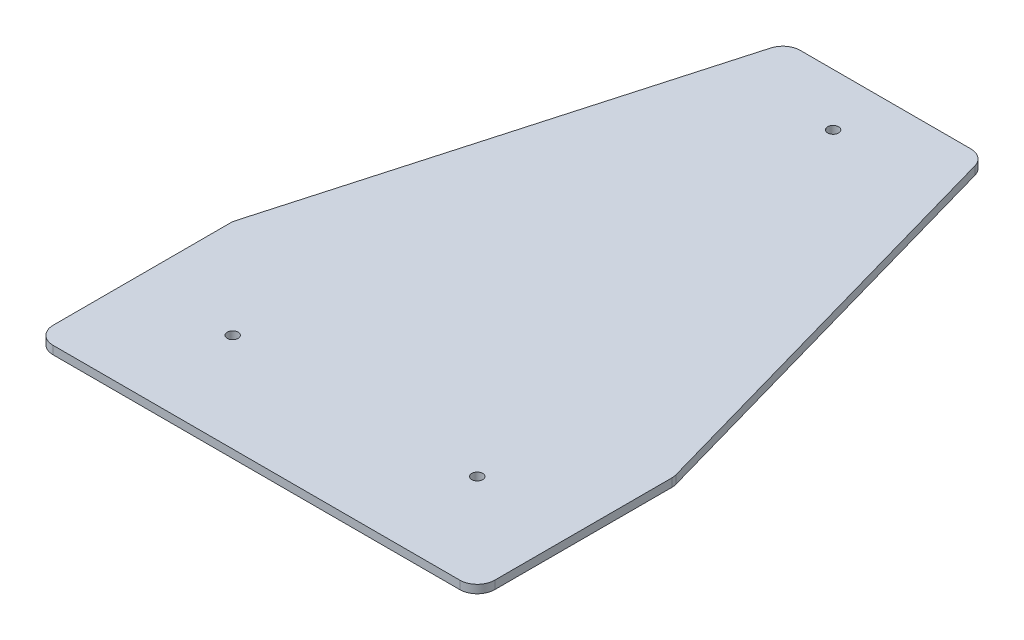
from build123d import *

# Parameters (mm, degrees)
BOSS_EXTRUDE1_DEPTH = 2.36
FILLET1_R           = 5
SKETCH4_R           = 1.5625
CUT_EXTRUDE1_DEPTH  = 3.36


with BuildPart() as part:
    # Sketch3 → Boss-Extrude1 (new body)
    with BuildSketch(Plane(origin=(0, 0, 0), x_dir=(1, 0, 0), z_dir=(0, 1, 0))):
        Polygon((-63.18, -28.18), (63.18, -28.18), (63.18, 28.18), (28.18, 151.82), (-28.18, 151.82), (-63.18, 28.18), align=None)
    extrude(amount=BOSS_EXTRUDE1_DEPTH)

    # Fillet1
    fillet1_edges = [part.edges().sort_by_distance(p)[0] for p in [
        (63.18, 1.18, -28.18),
        (63.18, 1.18, 28.18),
        (-63.18, 1.18, 28.18),
        (-63.18, 1.18, -28.18),
        (-28.18, 1.18, -151.82),
        (28.18, 1.18, -151.82),
    ]]
    fillet(fillet1_edges, radius=FILLET1_R)

    # Sketch4 → Cut-Extrude1 (cut, through all)
    with BuildSketch(Plane(origin=(0, 2.36, 0), x_dir=(1, 0, 0), z_dir=(0, 1, 0))):
        with Locations((-35, 0)):
            Circle(SKETCH4_R)
        with Locations((35, 0)):
            Circle(SKETCH4_R)
        with Locations((0, 136.82)):
            Circle(SKETCH4_R)
    extrude(amount=-CUT_EXTRUDE1_DEPTH, mode=Mode.SUBTRACT)


solid = part.part
